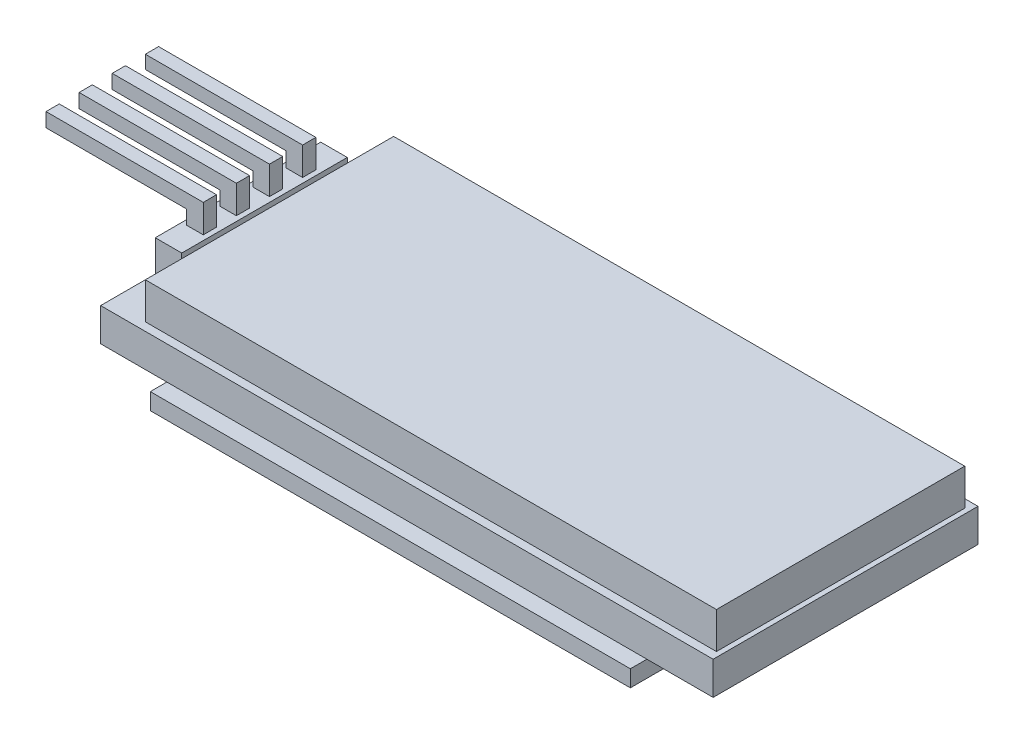
from build123d import *

# Parameters (mm, degrees)
SKETCH1_W                = 37
SKETCH1_H                = 16
BOSS_EXTRUDE1_DEPTH      = 2
SKETCH2_W                = 34.5
SKETCH2_H                = 15
BOSS_EXTRUDE2_DEPTH      = 2.2
SKETCH3_W                = 1.6
SKETCH3_H                = 10
BOSS_EXTRUDE3_DEPTH      = 2.2
SKETCH4_W                = 1
SKETCH4_H                = 0.8
BOSS_EXTRUDE4_DEPTH      = 1.7
BOSS_EXTRUDE4_DEPTH_BACK = 6
SKETCH5_W                = 0.8
SKETCH5_H                = 0.8
SKETCH5_H_2              = 0.85
BOSS_EXTRUDE5_DEPTH      = 8.5
SKETCH6_W                = 29
SKETCH6_H                = 18
BOSS_EXTRUDE6_DEPTH      = 1


with BuildPart() as part:
    # Sketch1 → Boss-Extrude1 (new body)
    with BuildSketch(Plane(origin=(0, 0, 0), x_dir=(1, 0, 0), z_dir=(0, 1, 0))):
        with Locations((18.5, 8)):
            Rectangle(SKETCH1_W, SKETCH1_H)
    extrude(amount=BOSS_EXTRUDE1_DEPTH)

    # Sketch2 → Boss-Extrude2 (add)
    with BuildSketch(Plane(origin=(0, 2, 0), x_dir=(1, 0, 0), z_dir=(0, 1, 0))):
        with Locations((19.45, 8)):
            Rectangle(SKETCH2_W, SKETCH2_H)
    extrude(amount=BOSS_EXTRUDE2_DEPTH)

    # Sketch3 → Boss-Extrude3 (add)
    with BuildSketch(Plane(origin=(0, 2, 0), x_dir=(1, 0, 0), z_dir=(0, 1, 0))):
        with Locations((1.1, 8)):
            Rectangle(SKETCH3_W, SKETCH3_H)
    extrude(amount=BOSS_EXTRUDE3_DEPTH)

    # Sketch4 → Boss-Extrude4 (add, two sides)
    with BuildSketch(Plane(origin=(0, 4.2, 0), x_dir=(1, 0, 0), z_dir=(0, 1, 0))) as boss_extrude4_sk:
        with Locations((1.1, 11)):
            Rectangle(SKETCH4_W, SKETCH4_H)
        with Locations((1.1, 9)):
            Rectangle(SKETCH4_W, SKETCH4_H)
        with Locations((1.1, 7)):
            Rectangle(SKETCH4_W, SKETCH4_H)
        with Locations((1.1, 5)):
            Rectangle(SKETCH4_W, SKETCH4_H)
    extrude(amount=BOSS_EXTRUDE4_DEPTH)
    extrude(boss_extrude4_sk.sketch, amount=-BOSS_EXTRUDE4_DEPTH_BACK)

    # Sketch5 → Boss-Extrude5 (add)
    with BuildSketch(Plane.ZY.offset(-0.6)):
        with Locations((-11, 5.5)):
            Rectangle(SKETCH5_W, SKETCH5_H)
        with Locations((-9, 5.475)):
            Rectangle(SKETCH5_W, SKETCH5_H_2)
        with Locations((-7, 5.475)):
            Rectangle(SKETCH5_W, SKETCH5_H_2)
        with Locations((-5, 5.475)):
            Rectangle(SKETCH5_W, SKETCH5_H_2)
    extrude(amount=BOSS_EXTRUDE5_DEPTH)

    # Sketch6 → Boss-Extrude6 (add)
    with BuildSketch(Plane(origin=(0, 0, 0), x_dir=(-1, 0, 0), z_dir=(0, -1, 0))):
        with Locations((-18.5, 8)):
            Rectangle(SKETCH6_W, SKETCH6_H)
    extrude(amount=BOSS_EXTRUDE6_DEPTH)


solid = part.part
